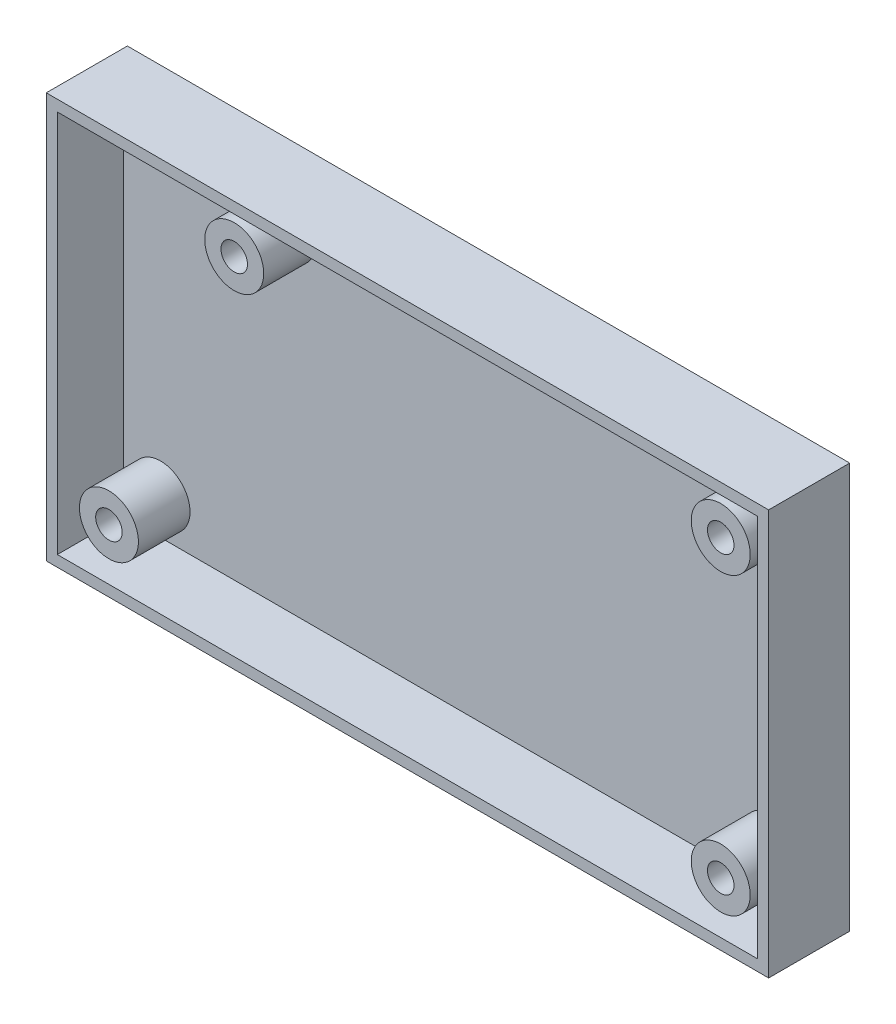
from build123d import *

# Parameters (mm, degrees)
SKETCH1_W           = 98
SKETCH1_H           = 55
BOSS_EXTRUDE1_DEPTH = 2
SKETCH2_W           = 98
SKETCH2_H           = 55
SKETCH2_W_2         = 95
SKETCH2_H_2         = 52
BOSS_EXTRUDE2_DEPTH = 9
SKETCH3_R           = 4
SKETCH3_R_2         = 1.8
BOSS_EXTRUDE3_DEPTH = 7


with BuildPart() as part:
    # Sketch1 → Boss-Extrude1 (new body)
    with BuildSketch(Plane.XY):
        with Locations((49, -27.5)):
            Rectangle(SKETCH1_W, SKETCH1_H)
    extrude(amount=BOSS_EXTRUDE1_DEPTH)

    # Sketch2 → Boss-Extrude2 (add)
    with BuildSketch(Plane.XY.offset(2)):
        with Locations((49, -27.5)):
            Rectangle(SKETCH2_W, SKETCH2_H)
        with Locations((49, -27.5)):
            Rectangle(SKETCH2_W_2, SKETCH2_H_2, mode=Mode.SUBTRACT)
    extrude(amount=BOSS_EXTRUDE2_DEPTH)

    # Sketch3 → Boss-Extrude3 (add)
    with BuildSketch(Plane.XY.offset(2)):
        with Locations((89.5, -8.5)):
            Circle(SKETCH3_R)
        with Locations((89.5, -8.5)):
            Circle(SKETCH3_R_2, mode=Mode.SUBTRACT)
        with Locations((89.5, -48.5)):
            Circle(SKETCH3_R)
        with Locations((89.5, -48.5)):
            Circle(SKETCH3_R_2, mode=Mode.SUBTRACT)
        with Locations((6.5, -48.5)):
            Circle(SKETCH3_R)
        with Locations((6.5, -48.5)):
            Circle(SKETCH3_R_2, mode=Mode.SUBTRACT)
        with Locations((23.5, -8.5)):
            Circle(SKETCH3_R)
        with Locations((23.5, -8.5)):
            Circle(SKETCH3_R_2, mode=Mode.SUBTRACT)
    extrude(amount=BOSS_EXTRUDE3_DEPTH)


solid = part.part
